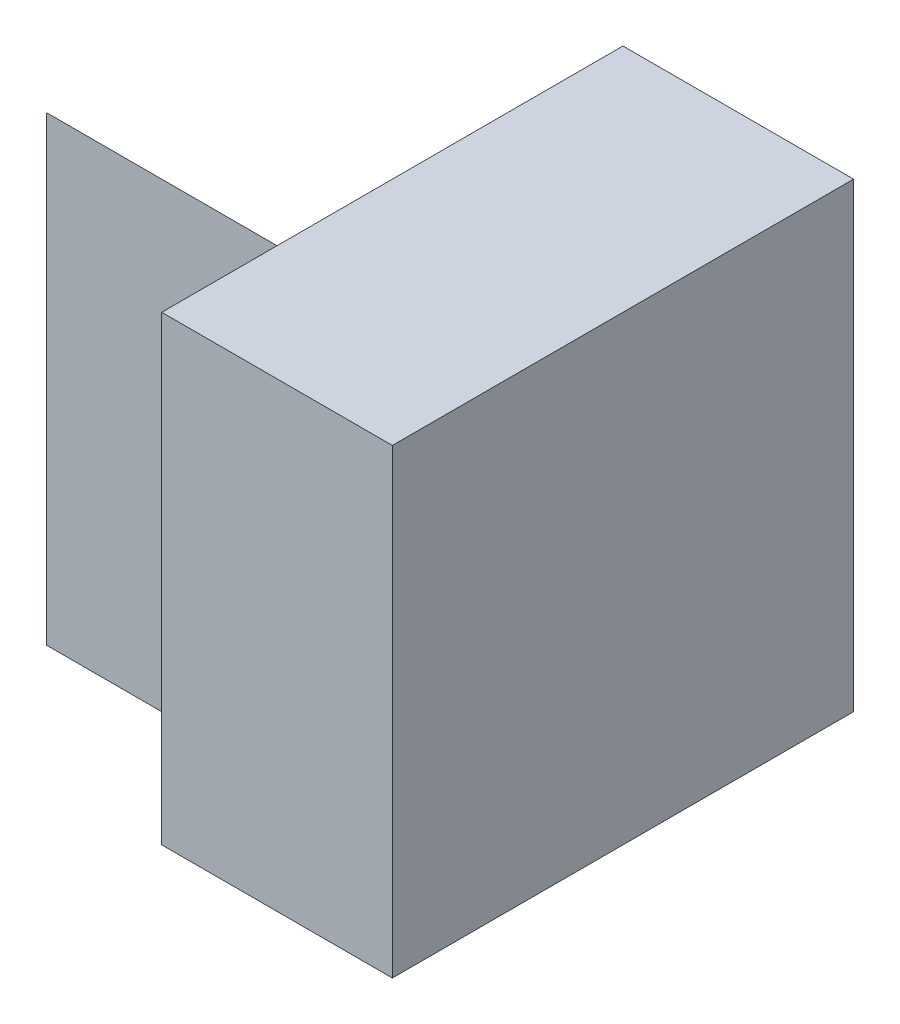
from build123d import *

# Parameters (mm, degrees)
SKETCH1_W           = 4
SKETCH1_H           = 4
BOSS_EXTRUDE1_DEPTH = 2
SKETCH2_W           = 3
SKETCH2_H           = 4
BOSS_EXTRUDE2_DEPTH = 2
CUT_EXTRUDE1_DEPTH  = 2


with BuildPart() as part:
    # Sketch1 → Boss-Extrude1 (new body)
    with BuildSketch(Plane(origin=(0, 0, 0), x_dir=(0, 0, -1), z_dir=(1, 0, 0))):
        with Locations((2, 2)):
            Rectangle(SKETCH1_W, SKETCH1_H)
    extrude(amount=BOSS_EXTRUDE1_DEPTH)

    # Sketch2 → Boss-Extrude2 (add)
    with BuildSketch(Plane.ZY):
        with Locations((-2.5, 2)):
            Rectangle(SKETCH2_W, SKETCH2_H)
    extrude(amount=BOSS_EXTRUDE2_DEPTH)

    # Sketch3 → Cut-Extrude1 (cut)
    with BuildSketch(Plane.ZY.offset(2)):
        Polygon((-1, 4), (-4, 0), (-4, 4), align=None)
    extrude(amount=-CUT_EXTRUDE1_DEPTH, mode=Mode.SUBTRACT)


solid = part.part
